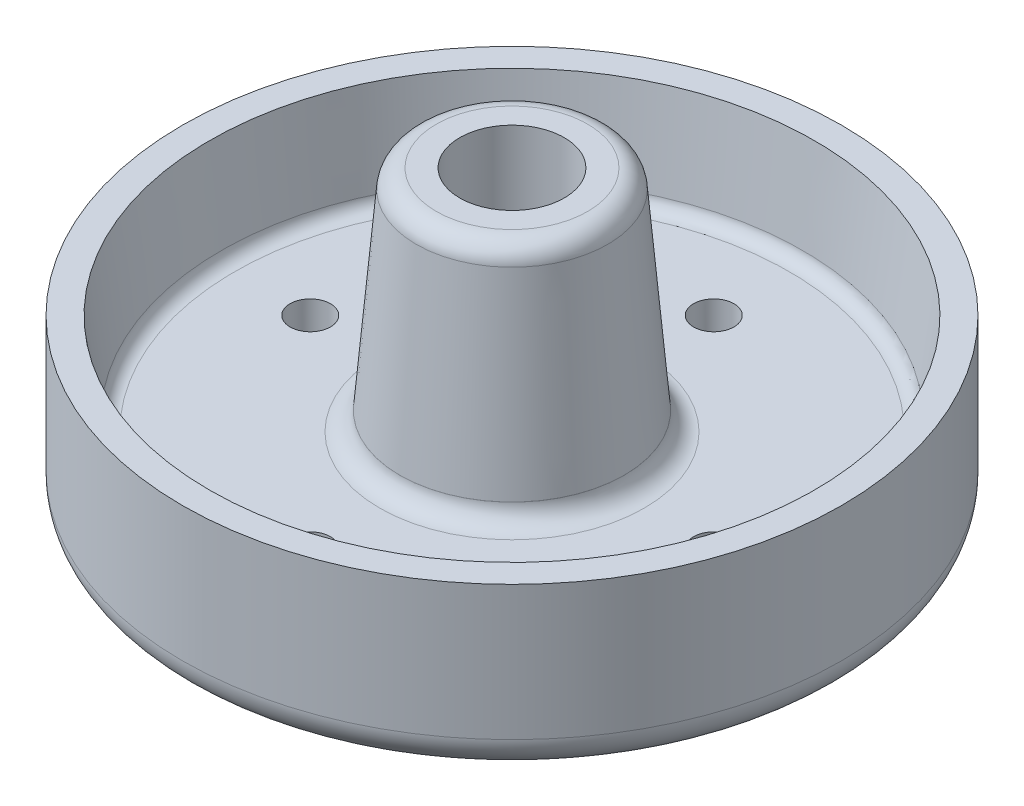
from build123d import *

# Parameters (mm, degrees)
CUT_EXTRUDE2_START = -45
SKETCH6_R          = 3
CUT_EXTRUDE2_DEPTH = 49
CIRPATTERN2_COUNT  = 4


with BuildPart() as part:
    # Sketch3 → Revolve3 (revolve)
    with BuildSketch(Plane.XY, mode=Mode.PRIVATE) as revolve3_sk:
        with BuildLine():
            Line((-11.253050324, 0), (-7.777152082, 0))
            Line((-7.777152082, 0), (-7.777152082, -47))
            Line((-7.777152082, -47), (-17, -47))
            Line((-17, -47), (-17, -44))
            Line((-17, -44), (-44, -44))
            ThreePointArc((-44, -44), (-47.535533906, -42.535533906), (-49, -39))
            Line((-49, -39), (-49, -19))
            Line((-49, -19), (-45, -19))
            Line((-45, -19), (-43.231423008, -32.26432744))
            ThreePointArc((-43.231423008, -32.26432744), (-42.566416469, -33.504768235), (-41.248967207, -34))
            Line((-41.248967207, -34), (-19.668701252, -34))
            ThreePointArc((-19.668701252, -34), (-17.645287665, -33.214903487), (-16.680924046, -31.270531637))
            Line((-16.680924046, -31.270531637), (-16.679706085, -31.256728077))
            Line((-16.679706085, -31.256728077), (-14.242146839, -2.744457398))
            ThreePointArc((-14.242146839, -2.744457398), (-13.282012151, -0.790177857), (-11.253050324, 0))
        make_face()
    revolve(revolve3_sk.sketch.rotate(Axis((0, 0, 0), (0, -1, 0)), 270), axis=Axis((0, 0, 0), (0, -1, 0)))  # turned: the seam where the file's is

    # Sketch6 → Cut-Extrude2 (cut)
    with BuildSketch(Plane.XZ.offset(44).offset(CUT_EXTRUDE2_START)):
        with Locations(Location((0, 30, 0), (0, 0, 270))):  # turned: the seam where the file's is
            Circle(SKETCH6_R)
    cut_extrude2 = extrude(amount=CUT_EXTRUDE2_DEPTH, mode=Mode.SUBTRACT)

    # CirPattern2: Cut-Extrude2 ×4 about axis
    cirpattern2_axis = Axis((0, 0, 0), (0, 1, 0))
    for i in range(1, CIRPATTERN2_COUNT):
        add(cut_extrude2.rotate(cirpattern2_axis, i * 360 / CIRPATTERN2_COUNT), mode=Mode.SUBTRACT)


solid = part.part
